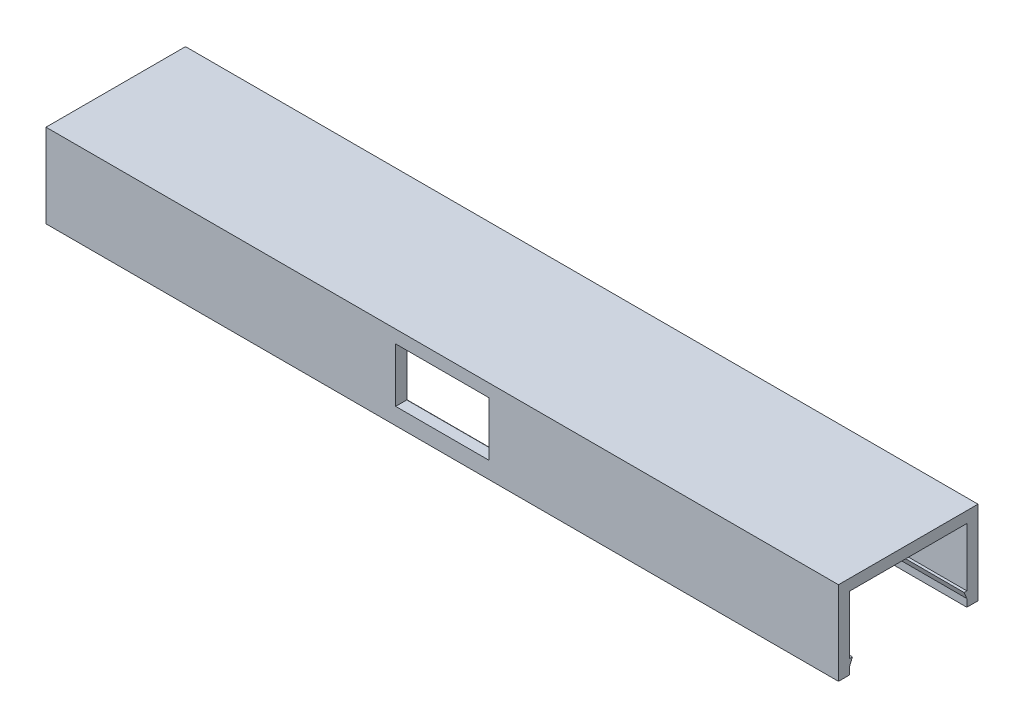
from build123d import *

# Parameters (mm, degrees)
CROQUIS1_W              = 142
CROQUIS1_H              = 20.7
CROQUIS1_H_2            = 2.15
SALIENTE_EXTRUIR1_DEPTH = 15
CROQUIS2_W              = 21
CROQUIS2_H              = 13
CORTAR_EXTRUIR1_DEPTH   = 230
SALIENTE_EXTRUIR4_DEPTH = 142
CROQUIS12_W             = 16.7
CROQUIS12_H             = 9.7
CORTAR_EXTRUIR2_DEPTH   = 10


with BuildPart() as part:
    # Croquis1 → Saliente-Extruir1 (new body)
    with BuildSketch(Plane(origin=(0, 0, 0), x_dir=(1, 0, 0), z_dir=(0, 1, 0))):
        Rectangle(CROQUIS1_W, CROQUIS1_H)
        with Locations((0, 11.425)):
            Rectangle(CROQUIS1_W, CROQUIS1_H_2)
        with Locations((0, -11.425)):
            Rectangle(CROQUIS1_W, CROQUIS1_H_2)
    extrude(amount=SALIENTE_EXTRUIR1_DEPTH)

    # Croquis2 → Cortar-Extruir1 (cut)
    with BuildSketch(Plane.ZY.offset(71)):
        with Locations((0, 6.5)):
            Rectangle(CROQUIS2_W, CROQUIS2_H)
    extrude(amount=-CORTAR_EXTRUIR1_DEPTH, mode=Mode.SUBTRACT)

    # Croquis11 → Saliente-Extruir4 (add)
    with BuildSketch(Plane.ZY.offset(71)):
        Polygon((-10.5, 1.35), (-10.5, 2.55), (-10, 2.55), align=None)
        Polygon((10, 2.55), (10.5, 1.35), (10.5, 2.55), align=None)
    extrude(amount=-SALIENTE_EXTRUIR4_DEPTH)

    # Croquis12 → Cortar-Extruir2 (cut)
    with BuildSketch(Plane.XY.offset(12.5)):
        with Locations((0, 7.85)):
            Rectangle(CROQUIS12_W, CROQUIS12_H)
    extrude(amount=-CORTAR_EXTRUIR2_DEPTH, mode=Mode.SUBTRACT)


solid = part.part
